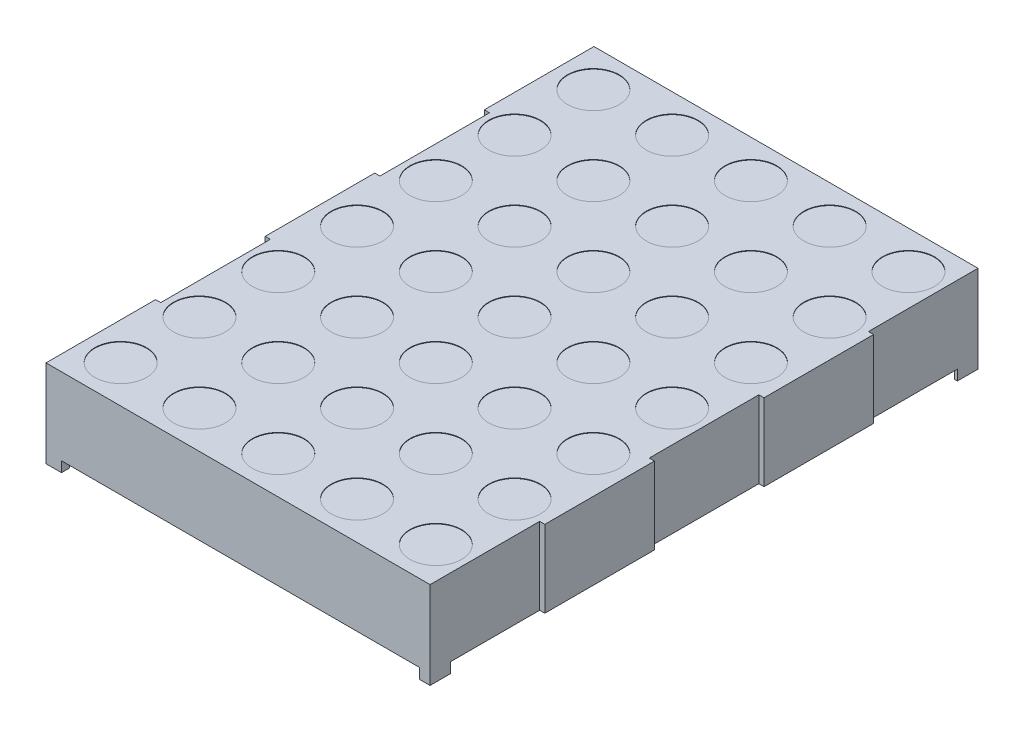
from build123d import *

# Parameters (mm, degrees)
EXTRUDE1_DEPTH     = 18.825
SKETCH3_W          = 34.65
SKETCH3_H          = 1
CUT_EXTRUDE1_DEPTH = 54
SKETCH2_R          = 2.5
CUT_EXTRUDE2_DEPTH = 0.05
SKETCH4_R          = 0.25
EXTRUDE2_DEPTH     = 1
SKETCH4_3_R        = 0.25
EXTRUDE3_DEPTH     = 4
SKETCH4_4_W        = 0.75
SKETCH4_4_H        = 1.25
CUT_EXTRUDE3_DEPTH = 1
SKETCH2_4_W        = 0.5
SKETCH2_4_H        = 10.6
CUT_EXTRUDE5_DEPTH = 13.45
SKETCH5_W          = 0.025316456
SKETCH5_H          = 0.026582278
CUT_EXTRUDE6_DEPTH = 0.01


with BuildPart() as part:
    # Sketch1 → Extrude1 (new body, symmetric)
    with BuildSketch(Plane(origin=(0, 0, 0), x_dir=(0, 0, -1), z_dir=(1, 0, 0))):
        Polygon((26.5, 4.225), (-26.5, 4.225), (20.227810651, -3.225), (24.5, -3.225), (24.5, -3.906132075), (26.5, -4.225), align=None)
        Polygon((20.227810651, -3.225), (-26.5, 4.225), (-26.5, -4.225), (-24.5, -4.225), (-24.5, -3.225), align=None)
        Polygon((26.5, -4.225), (24.5, -3.906132075), (24.5, -4.225), align=None)
    extrude(amount=EXTRUDE1_DEPTH, both=True)

    # Sketch3 → Cut-Extrude1 (cut, through all)
    with BuildSketch(Plane.XY.offset(26.5)):
        with Locations((0, -3.725)):
            Rectangle(SKETCH3_W, SKETCH3_H)
    extrude(amount=-CUT_EXTRUDE1_DEPTH, mode=Mode.SUBTRACT)

    # Sketch2 → Cut-Extrude2 (cut)
    with BuildSketch(Plane(origin=(0, 4.225, 0), x_dir=(-1, 0, 0), z_dir=(0, 1, 0))):
        with Locations(Location((15.24, -22.86, 0), (0, 0, 90))):  # turned: the seam where the file's is
            Circle(SKETCH2_R)
        with Locations(Location((7.62, -22.86, 0), (0, 0, 90))):  # turned: the seam where the file's is
            Circle(SKETCH2_R)
        with Locations(Location((0, -22.86, 0), (0, 0, 90))):  # turned: the seam where the file's is
            Circle(SKETCH2_R)
        with Locations(Location((-7.62, -22.86, 0), (0, 0, 90))):  # turned: the seam where the file's is
            Circle(SKETCH2_R)
        with Locations(Location((-15.24, -22.86, 0), (0, 0, 90))):  # turned: the seam where the file's is
            Circle(SKETCH2_R)
        with Locations(Location((-15.24, -15.24, 0), (0, 0, 90))):  # turned: the seam where the file's is
            Circle(SKETCH2_R)
        with Locations(Location((-7.62, -15.24, 0), (0, 0, 90))):  # turned: the seam where the file's is
            Circle(SKETCH2_R)
        with Locations(Location((0, -15.24, 0), (0, 0, 90))):  # turned: the seam where the file's is
            Circle(SKETCH2_R)
        with Locations(Location((7.62, -15.24, 0), (0, 0, 90))):  # turned: the seam where the file's is
            Circle(SKETCH2_R)
        with Locations(Location((15.24, -15.24, 0), (0, 0, 90))):  # turned: the seam where the file's is
            Circle(SKETCH2_R)
        with Locations(Location((15.24, -7.62, 0), (0, 0, 90))):  # turned: the seam where the file's is
            Circle(SKETCH2_R)
        with Locations(Location((7.62, -7.62, 0), (0, 0, 90))):  # turned: the seam where the file's is
            Circle(SKETCH2_R)
        with Locations(Location((0, -7.62, 0), (0, 0, 90))):  # turned: the seam where the file's is
            Circle(SKETCH2_R)
        with Locations(Location((-7.62, -7.62, 0), (0, 0, 90))):  # turned: the seam where the file's is
            Circle(SKETCH2_R)
        with Locations(Location((-15.24, -7.62, 0), (0, 0, 90))):  # turned: the seam where the file's is
            Circle(SKETCH2_R)
        with Locations(Location((-15.24, 0, 0), (0, 0, 90))):  # turned: the seam where the file's is
            Circle(SKETCH2_R)
        with Locations(Location((-7.62, 0, 0), (0, 0, 90))):  # turned: the seam where the file's is
            Circle(SKETCH2_R)
        with Locations(Location((0, 0, 0), (0, 0, 90))):  # turned: the seam where the file's is
            Circle(SKETCH2_R)
        with Locations(Location((7.62, 0, 0), (0, 0, 90))):  # turned: the seam where the file's is
            Circle(SKETCH2_R)
        with Locations(Location((15.24, 0, 0), (0, 0, 90))):  # turned: the seam where the file's is
            Circle(SKETCH2_R)
        with Locations(Location((15.24, 7.62, 0), (0, 0, 90))):  # turned: the seam where the file's is
            Circle(SKETCH2_R)
        with Locations(Location((7.62, 7.62, 0), (0, 0, 90))):  # turned: the seam where the file's is
            Circle(SKETCH2_R)
        with Locations(Location((0, 7.62, 0), (0, 0, 90))):  # turned: the seam where the file's is
            Circle(SKETCH2_R)
        with Locations(Location((-7.62, 7.62, 0), (0, 0, 90))):  # turned: the seam where the file's is
            Circle(SKETCH2_R)
        with Locations(Location((-15.24, 7.62, 0), (0, 0, 90))):  # turned: the seam where the file's is
            Circle(SKETCH2_R)
        with Locations(Location((-15.24, 15.24, 0), (0, 0, 90))):  # turned: the seam where the file's is
            Circle(SKETCH2_R)
        with Locations(Location((-7.62, 15.24, 0), (0, 0, 90))):  # turned: the seam where the file's is
            Circle(SKETCH2_R)
        with Locations(Location((0, 15.24, 0), (0, 0, 90))):  # turned: the seam where the file's is
            Circle(SKETCH2_R)
        with Locations(Location((7.62, 15.24, 0), (0, 0, 90))):  # turned: the seam where the file's is
            Circle(SKETCH2_R)
        with Locations(Location((15.24, 15.24, 0), (0, 0, 90))):  # turned: the seam where the file's is
            Circle(SKETCH2_R)
        with Locations(Location((15.24, 22.86, 0), (0, 0, 90))):  # turned: the seam where the file's is
            Circle(SKETCH2_R)
        with Locations(Location((7.62, 22.86, 0), (0, 0, 90))):  # turned: the seam where the file's is
            Circle(SKETCH2_R)
        with Locations(Location((0, 22.86, 0), (0, 0, 90))):  # turned: the seam where the file's is
            Circle(SKETCH2_R)
        with Locations(Location((-7.62, 22.86, 0), (0, 0, 90))):  # turned: the seam where the file's is
            Circle(SKETCH2_R)
        with Locations(Location((-15.24, 22.86, 0), (0, 0, 90))):  # turned: the seam where the file's is
            Circle(SKETCH2_R)
    extrude(amount=-CUT_EXTRUDE2_DEPTH, mode=Mode.SUBTRACT)

    # Sketch4 → Extrude2 (add)
    with BuildSketch(Plane.XZ.offset(4.225)):
        with Locations((-7.62, 19.05)):
            Circle(SKETCH4_R)
        with Locations(Location((-5.08, 19.05, 0), (0, 0, 270))):  # turned: the seam where the file's is
            Circle(SKETCH4_R)
        with Locations(Location((-2.54, 19.05, 0), (0, 0, 270))):  # turned: the seam where the file's is
            Circle(SKETCH4_R)
        with Locations(Location((7.62, 19.05, 0), (0, 0, 270))):  # turned: the seam where the file's is
            Circle(SKETCH4_R)
        with Locations(Location((0, 19.05, 0), (0, 0, 270))):  # turned: the seam where the file's is
            Circle(SKETCH4_R)
        with Locations(Location((2.54, 19.05, 0), (0, 0, 270))):  # turned: the seam where the file's is
            Circle(SKETCH4_R)
        with Locations(Location((5.08, 19.05, 0), (0, 0, 270))):  # turned: the seam where the file's is
            Circle(SKETCH4_R)
        with Locations(Location((5.08, -19.05, 0), (0, 0, 270))):  # turned: the seam where the file's is
            Circle(SKETCH4_R)
        with Locations(Location((2.54, -19.05, 0), (0, 0, 270))):  # turned: the seam where the file's is
            Circle(SKETCH4_R)
        with Locations(Location((0, -19.05, 0), (0, 0, 270))):  # turned: the seam where the file's is
            Circle(SKETCH4_R)
        with Locations(Location((7.62, -19.05, 0), (0, 0, 270))):  # turned: the seam where the file's is
            Circle(SKETCH4_R)
        with Locations(Location((-2.54, -19.05, 0), (0, 0, 270))):  # turned: the seam where the file's is
            Circle(SKETCH4_R)
        with Locations(Location((-5.08, -19.05, 0), (0, 0, 270))):  # turned: the seam where the file's is
            Circle(SKETCH4_R)
        with Locations(Location((-7.62, -19.05, 0), (0, 0, 270))):  # turned: the seam where the file's is
            Circle(SKETCH4_R)
    extrude(amount=-EXTRUDE2_DEPTH)

    # Sketch4_3 → Extrude3 (add)
    with BuildSketch(Plane.XZ.offset(4.225)):
        with Locations((-7.62, 19.05)):
            Circle(SKETCH4_3_R)
        with Locations((-5.08, 19.05)):
            Circle(SKETCH4_3_R)
        with Locations((-2.54, 19.05)):
            Circle(SKETCH4_3_R)
        with Locations((7.62, 19.05)):
            Circle(SKETCH4_3_R)
        with Locations((0, 19.05)):
            Circle(SKETCH4_3_R)
        with Locations((2.54, 19.05)):
            Circle(SKETCH4_3_R)
        with Locations(Location((5.08, 19.05, 0), (0, 0, 270))):  # turned: the seam where the file's is
            Circle(SKETCH4_3_R)
        with Locations(Location((5.08, -19.05, 0), (0, 0, 180))):  # turned: the seam where the file's is
            Circle(SKETCH4_3_R)
        with Locations(Location((2.54, -19.05, 0), (0, 0, 180))):  # turned: the seam where the file's is
            Circle(SKETCH4_3_R)
        with Locations(Location((0, -19.05, 0), (0, 0, 180))):  # turned: the seam where the file's is
            Circle(SKETCH4_3_R)
        with Locations(Location((7.62, -19.05, 0), (0, 0, 180))):  # turned: the seam where the file's is
            Circle(SKETCH4_3_R)
        with Locations(Location((-2.54, -19.05, 0), (0, 0, 270))):  # turned: the seam where the file's is
            Circle(SKETCH4_3_R)
        with Locations(Location((-5.08, -19.05, 0), (0, 0, 270))):  # turned: the seam where the file's is
            Circle(SKETCH4_3_R)
        with Locations(Location((-7.62, -19.05, 0), (0, 0, 270))):  # turned: the seam where the file's is
            Circle(SKETCH4_3_R)
    extrude(amount=EXTRUDE3_DEPTH)

    # Sketch4_4 → Cut-Extrude3 (cut)
    with BuildSketch(Plane.XZ.offset(4.225)):
        with Locations((-17.7, 25.125)):
            Rectangle(SKETCH4_4_W, SKETCH4_4_H)
        with Locations((17.7, 25.125)):
            Rectangle(SKETCH4_4_W, SKETCH4_4_H)
        with Locations((17.7, -25.125)):
            Rectangle(SKETCH4_4_W, SKETCH4_4_H)
        with Locations((-17.7, -25.125)):
            Rectangle(SKETCH4_4_W, SKETCH4_4_H)
    extrude(amount=-CUT_EXTRUDE3_DEPTH, mode=Mode.SUBTRACT)

    # Sketch2_4 → Cut-Extrude5 (cut, through all)
    with BuildSketch(Plane(origin=(0, 4.225, 0), x_dir=(-1, 0, 0), z_dir=(0, 1, 0))):
        with Locations((18.575, -10.6)):
            Rectangle(SKETCH2_4_W, SKETCH2_4_H)
        with Locations((18.575, 10.6)):
            Rectangle(SKETCH2_4_W, SKETCH2_4_H)
        with Locations((-18.575, 21.2)):
            Rectangle(SKETCH2_4_W, SKETCH2_4_H)
        with Locations((-18.575, 0)):
            Rectangle(SKETCH2_4_W, SKETCH2_4_H)
        with Locations((-18.575, -21.2)):
            Rectangle(SKETCH2_4_W, SKETCH2_4_H)
    extrude(amount=-CUT_EXTRUDE5_DEPTH, mode=Mode.SUBTRACT)

    # Sketch5 → Cut-Extrude6 (cut)
    with BuildSketch(Plane.XZ.offset(3.225)):
        Polygon((0.322151899, 18.267512561), (0.345609177, 18.342196105), (0.370352057, 18.342196105), (0.386768196, 18.291859871), (0.402294304, 18.342196105), (0.428026108, 18.342196105), (0.451265823, 18.267512561), (0.426087816, 18.267512561), (0.413093354, 18.318995947), (0.396677215, 18.267512561), (0.375178006, 18.267512561), (0.358860759, 18.318995947), (0.346044304, 18.267512561), align=None)
        Polygon((0.187974684, 18.267512561), (0.211431962, 18.342196105), (0.236174842, 18.342196105), (0.252590981, 18.291859871), (0.268117089, 18.342196105), (0.293848892, 18.342196105), (0.317088608, 18.267512561), (0.291910601, 18.267512561), (0.278916139, 18.318995947), (0.2625, 18.267512561), (0.241000791, 18.267512561), (0.224683544, 18.318995947), (0.211867089, 18.267512561), align=None)
        Polygon((0.053797468, 18.267512561), (0.077254747, 18.342196105), (0.101997627, 18.342196105), (0.118413766, 18.291859871), (0.133939873, 18.342196105), (0.159671677, 18.342196105), (0.182911392, 18.267512561), (0.157733386, 18.267512561), (0.144738924, 18.318995947), (0.128322785, 18.267512561), (0.106823576, 18.267512561), (0.090506329, 18.318995947), (0.077689873, 18.267512561), align=None)
        with Locations((0.025949367, 18.328904966)):
            Rectangle(SKETCH5_W, SKETCH5_H)
        with BuildLine():
            add(Edge.make_bspline(
                [(-0.090506329, 18.311025219), (-0.090469801, 18.312247334), (-0.090398072, 18.314647158), (-0.08978891, 18.318155124), (-0.088793386, 18.321478407), (-0.087429047, 18.324641123), (-0.085615059, 18.327596489), (-0.083460046, 18.330415056), (-0.080848131, 18.332999017), (-0.077911095, 18.335437779), (-0.074613168, 18.337620173), (-0.071010546, 18.339520312), (-0.067140226, 18.34114503), (-0.062986206, 18.34247672), (-0.058540628, 18.343467487), (-0.053822851, 18.344190805), (-0.048829503, 18.344664312), (-0.045405915, 18.344706254), (-0.043651108, 18.344727751)],
                knots=[0, 0, 0, 0, 0.907421153, 1.781872267, 2.635683434, 3.480115191, 4.332689235, 5.205575272, 6.109500117, 7.055808355, 8.037942167, 9.041423561, 10.07750834, 11.152467461, 12.277657752, 13.45734338, 14.696726425, 16, 16, 16, 16], degree=3))
            add(Edge.make_bspline(
                [(-0.043651108, 18.344727751), (-0.041633123, 18.344700486), (-0.037724937, 18.344647683), (-0.032057369, 18.344262309), (-0.026793902, 18.34357436), (-0.021896155, 18.342617779), (-0.017291855, 18.341414494), (-0.01285851, 18.34012385), (-0.008577218, 18.33865927), (-0.005804126, 18.337559134), (-0.00443038, 18.337014143)],
                knots=[0, 0, 0, 0, 1.203182053, 2.33017619, 3.384818652, 4.366208123, 5.30340534, 6.221361684, 7.118890722, 8, 8, 8, 8], degree=3))
            Line((-0.00443038, 18.337014143), (-0.00443038, 18.313082181))
            Line((-0.00443038, 18.313082181), (-0.007278481, 18.313082181))
            add(Edge.make_bspline(
                [(-0.007278481, 18.313082181), (-0.008644044, 18.314163144), (-0.011367154, 18.316318723), (-0.015794112, 18.319087078), (-0.020453124, 18.321460088), (-0.025291518, 18.323442711), (-0.030192886, 18.325018325), (-0.035061954, 18.32614523), (-0.039830936, 18.326884595), (-0.042989258, 18.326966156), (-0.044541139, 18.327006232)],
                knots=[0, 0, 0, 0, 1.030738938, 2.055426519, 3.085610749, 4.123842265, 5.148648843, 6.130724483, 7.081507926, 8, 8, 8, 8], degree=3))
            add(Edge.make_bspline(
                [(-0.044541139, 18.327006232), (-0.044969885, 18.327004931), (-0.045887798, 18.327002147), (-0.047356946, 18.326880832), (-0.049013289, 18.326752988), (-0.050794028, 18.326556873), (-0.052581232, 18.326325729), (-0.05424148, 18.325979261), (-0.055742242, 18.32561011), (-0.056648911, 18.325242845), (-0.057080696, 18.325067941)],
                knots=[0, 0, 0, 0, 0.806537132, 1.726733348, 2.77251655, 3.932999672, 5.098049949, 6.161349231, 7.124375527, 8, 8, 8, 8], degree=3))
            add(Edge.make_bspline(
                [(-0.057080696, 18.325067941), (-0.057560183, 18.324839705), (-0.058502475, 18.324391174), (-0.059805006, 18.323577264), (-0.060975491, 18.322682519), (-0.062036193, 18.321720786), (-0.062898588, 18.320557798), (-0.063519749, 18.319158527), (-0.06386432, 18.317509234), (-0.063903392, 18.316334072), (-0.063924051, 18.315712719)],
                knots=[0, 0, 0, 0, 1.02474257, 2.013837243, 2.958431669, 3.867978675, 4.769292696, 5.732237074, 6.800947934, 8, 8, 8, 8], degree=3))
            add(Edge.make_bspline(
                [(-0.063924051, 18.315712719), (-0.063892589, 18.315166853), (-0.063830727, 18.314093519), (-0.063249221, 18.31256509), (-0.062365174, 18.311144954), (-0.061085759, 18.309879617), (-0.059472081, 18.308753505), (-0.057541093, 18.307742742), (-0.055267243, 18.306906985), (-0.05363003, 18.306469113), (-0.052768987, 18.306238827)],
                knots=[0, 0, 0, 0, 0.825427492, 1.623033598, 2.45033906, 3.348940377, 4.33183287, 5.428402891, 6.647546779, 8, 8, 8, 8], degree=3))
            add(Edge.make_bspline(
                [(-0.052768987, 18.306238827), (-0.050799747, 18.305793622), (-0.046764535, 18.304881344), (-0.040624722, 18.30369389), (-0.034486019, 18.302468019), (-0.030529762, 18.301253705), (-0.028599684, 18.300661295)],
                knots=[0, 0, 0, 0, 0.976118991, 2.000185432, 3.024380873, 4, 4, 4, 4], degree=3))
            add(Edge.make_bspline(
                [(-0.028599684, 18.300661295), (-0.027561531, 18.300307573), (-0.025540669, 18.299619018), (-0.022641477, 18.29846637), (-0.019998229, 18.297161235), (-0.01754069, 18.295839197), (-0.015348026, 18.29435914), (-0.013353392, 18.292826381), (-0.011600732, 18.291173576), (-0.010074294, 18.289424084), (-0.008731428, 18.287587722), (-0.007578018, 18.28564058), (-0.006616996, 18.283574131), (-0.005793604, 18.281418733), (-0.005182377, 18.279144198), (-0.004759941, 18.276767781), (-0.004461878, 18.274284295), (-0.004441022, 18.272589959), (-0.00443038, 18.271725378)],
                knots=[0, 0, 0, 0, 1.287376879, 2.505999703, 3.65855109, 4.746193839, 5.778582289, 6.760029101, 7.696159662, 8.601061861, 9.48181646, 10.363080883, 11.252765705, 12.153987336, 13.068239035, 14.012364187, 14.985753787, 16, 16, 16, 16], degree=3))
            add(Edge.make_bspline(
                [(-0.00443038, 18.271725378), (-0.00446768, 18.270569231), (-0.004541087, 18.268293956), (-0.005142537, 18.264964934), (-0.006169047, 18.261816115), (-0.007555407, 18.258812959), (-0.0093829, 18.255998696), (-0.011575023, 18.25332121), (-0.014185333, 18.250828713), (-0.01717066, 18.248530077), (-0.020457507, 18.246451271), (-0.023991512, 18.244614564), (-0.027770364, 18.243108116), (-0.031750249, 18.241826885), (-0.035969641, 18.24087449), (-0.040406612, 18.240154912), (-0.045080474, 18.239741912), (-0.048271885, 18.239690636), (-0.049901108, 18.23966446)],
                knots=[0, 0, 0, 0, 0.894901293, 1.761149761, 2.608783409, 3.453876344, 4.314933854, 5.200038827, 6.12799933, 7.103249695, 8.113098521, 9.136064399, 10.182719798, 11.259667356, 12.370545059, 13.528828137, 14.738461593, 16, 16, 16, 16], degree=3))
            add(Edge.make_bspline(
                [(-0.049901108, 18.23966446), (-0.051569759, 18.239686853), (-0.054904233, 18.2397316), (-0.059886206, 18.24010657), (-0.064843621, 18.240673071), (-0.069715185, 18.241472525), (-0.074397692, 18.242490181), (-0.078814306, 18.243576139), (-0.082893276, 18.244816529), (-0.085467001, 18.245770575), (-0.086708861, 18.246230916)],
                knots=[0, 0, 0, 0, 1.065379838, 2.128953261, 3.188461447, 4.250817766, 5.279613205, 6.247547721, 7.154416075, 8, 8, 8, 8], degree=3))
            Line((-0.086708861, 18.246230916), (-0.086708861, 18.268778384))
            Line((-0.086708861, 18.268778384), (-0.083880538, 18.268778384))
            add(Edge.make_bspline(
                [(-0.083880538, 18.268778384), (-0.082807578, 18.26797818), (-0.080613348, 18.266341742), (-0.076954595, 18.264255766), (-0.072990535, 18.262306252), (-0.068725633, 18.260584458), (-0.064253093, 18.259163858), (-0.059675547, 18.258134813), (-0.055048482, 18.25749569), (-0.051946891, 18.257422558), (-0.05039557, 18.257385979)],
                knots=[0, 0, 0, 0, 0.89224925, 1.824673196, 2.804309561, 3.838364047, 4.890042674, 5.931526337, 6.965412421, 8, 8, 8, 8], degree=3))
            add(Edge.make_bspline(
                [(-0.05039557, 18.257385979), (-0.04930027, 18.257410189), (-0.047110524, 18.257458589), (-0.043836117, 18.257807843), (-0.040601325, 18.258479585), (-0.038558427, 18.259293921), (-0.037539557, 18.259700061)],
                knots=[0, 0, 0, 0, 0.998993879, 1.997209027, 3.00113285, 4, 4, 4, 4], degree=3))
            add(Edge.make_bspline(
                [(-0.037539557, 18.259700061), (-0.037106078, 18.259901544), (-0.036239408, 18.260304375), (-0.035032405, 18.261076701), (-0.033929101, 18.262006419), (-0.032928096, 18.263058813), (-0.03208004, 18.264228147), (-0.03144238, 18.265497907), (-0.031081561, 18.266859885), (-0.031035724, 18.267794054), (-0.031012658, 18.268264143)],
                knots=[0, 0, 0, 0, 1.005454979, 2.010239304, 3.005296729, 4.036100111, 5.060531193, 6.034954812, 7.011155677, 8, 8, 8, 8], degree=3))
            add(Edge.make_bspline(
                [(-0.031012658, 18.268264143), (-0.031047453, 18.268902074), (-0.031113941, 18.270121102), (-0.031713939, 18.271834799), (-0.032711608, 18.27329791), (-0.033864707, 18.274290904), (-0.034981686, 18.274989664), (-0.036022203, 18.275494903), (-0.037221654, 18.276008326), (-0.038599103, 18.276497523), (-0.040134238, 18.27699157), (-0.04184316, 18.27746624), (-0.043725768, 18.277915799), (-0.045041658, 18.278201951), (-0.045727848, 18.278351169)],
                knots=[0, 0, 0, 0, 1.174343879, 2.244064321, 3.303704314, 4.407076671, 5.02483983, 5.732197225, 6.53898402, 7.431906431, 8.428480183, 9.514816237, 10.704066255, 12, 12, 12, 12], degree=3))
            add(Edge.make_bspline(
                [(-0.045727848, 18.278351169), (-0.047560473, 18.278727889), (-0.051161176, 18.279468061), (-0.056566251, 18.280562358), (-0.062059305, 18.281874875), (-0.065729855, 18.283004087), (-0.067642405, 18.283592466)],
                knots=[0, 0, 0, 0, 0.995788186, 1.956503735, 2.935230479, 4, 4, 4, 4], degree=3))
            add(Edge.make_bspline(
                [(-0.067642405, 18.283592466), (-0.068588962, 18.283911708), (-0.070440579, 18.284536195), (-0.073081177, 18.285622514), (-0.07552835, 18.286796371), (-0.077794984, 18.28803834), (-0.07987035, 18.289380774), (-0.08175664, 18.290806107), (-0.083454597, 18.292310889), (-0.084943345, 18.293926609), (-0.086272103, 18.295636958), (-0.087384447, 18.297487571), (-0.088380032, 18.299431099), (-0.089133187, 18.301524543), (-0.089757696, 18.30372307), (-0.090179439, 18.306055005), (-0.090473802, 18.308499223), (-0.090495366, 18.310173822), (-0.090506329, 18.311025219)],
                knots=[0, 0, 0, 0, 1.237326419, 2.420410185, 3.534642089, 4.598489486, 5.620241961, 6.59385002, 7.525152549, 8.426792174, 9.312230456, 10.203151844, 11.098070343, 12.012931196, 12.954244379, 13.926618287, 14.945853925, 16, 16, 16, 16], degree=3))
        make_face()
        with BuildLine():
            Line((-0.182911392, 18.342196105), (-0.158860759, 18.342196105))
            Line((-0.158860759, 18.342196105), (-0.158860759, 18.334363827))
            add(Edge.make_bspline(
                [(-0.158860759, 18.334363827), (-0.157767566, 18.335172622), (-0.155659904, 18.336731967), (-0.152485345, 18.338809028), (-0.149467045, 18.340593451), (-0.146536693, 18.342116568), (-0.143530416, 18.343328739), (-0.140292282, 18.344147119), (-0.136790686, 18.344649843), (-0.134363616, 18.344701205), (-0.133109177, 18.344727751)],
                knots=[0, 0, 0, 0, 1.150945962, 2.219006967, 3.209666795, 4.118194914, 5.012574058, 5.946577101, 6.93868214, 8, 8, 8, 8], degree=3))
            add(Edge.make_bspline(
                [(-0.133109177, 18.344727751), (-0.132092902, 18.344704803), (-0.130113921, 18.344660117), (-0.127235622, 18.344318396), (-0.124533656, 18.343769987), (-0.122004819, 18.343001581), (-0.119655119, 18.34199855), (-0.117511439, 18.340726915), (-0.115508862, 18.339294202), (-0.113726915, 18.337587836), (-0.112111369, 18.335689917), (-0.110728798, 18.333557508), (-0.109551093, 18.331224569), (-0.108609993, 18.328672719), (-0.107854904, 18.325914414), (-0.107330972, 18.322935167), (-0.107010379, 18.319748039), (-0.10697844, 18.317552909), (-0.106962025, 18.316424745)],
                knots=[0, 0, 0, 0, 1.108959949, 2.159465255, 3.158589008, 4.114545495, 5.039534357, 5.93921201, 6.830099133, 7.720870013, 8.624681761, 9.544731627, 10.487599671, 11.471264588, 12.508152322, 13.604835107, 14.769030043, 16, 16, 16, 16], degree=3))
            Line((-0.106962025, 18.316424745), (-0.106962025, 18.267512561))
            Line((-0.106962025, 18.267512561), (-0.131012658, 18.267512561))
            Line((-0.131012658, 18.267512561), (-0.131012658, 18.305091675))
            add(Edge.make_bspline(
                [(-0.131012658, 18.305091675), (-0.131014294, 18.306008146), (-0.131017424, 18.307762362), (-0.131099763, 18.310268168), (-0.131220664, 18.312536341), (-0.131359369, 18.314578369), (-0.131612385, 18.31642512), (-0.131990094, 18.318091281), (-0.13246092, 18.319610883), (-0.132925239, 18.320517585), (-0.133148734, 18.320954017)],
                knots=[0, 0, 0, 0, 1.361401701, 2.605856924, 3.723918663, 4.735739235, 5.645738665, 6.489217889, 7.27279937, 8, 8, 8, 8], degree=3))
            add(Edge.make_bspline(
                [(-0.133148734, 18.320954017), (-0.133378743, 18.321352723), (-0.13383092, 18.322136544), (-0.134751184, 18.323142855), (-0.135830026, 18.323986605), (-0.13710723, 18.324644706), (-0.138596797, 18.325135209), (-0.140317656, 18.325515781), (-0.142309397, 18.325687658), (-0.143716865, 18.325722149), (-0.144462025, 18.325740409)],
                knots=[0, 0, 0, 0, 0.849004071, 1.669068917, 2.503060811, 3.370079215, 4.310762265, 5.396376419, 6.621555549, 8, 8, 8, 8], degree=3))
            add(Edge.make_bspline(
                [(-0.144462025, 18.325740409), (-0.145002968, 18.32572057), (-0.146114384, 18.325679809), (-0.147831837, 18.325488268), (-0.149621097, 18.325089109), (-0.152139766, 18.324444164), (-0.155304975, 18.32325031), (-0.15766451, 18.321897163), (-0.158860759, 18.321211137)],
                knots=[0, 0, 0, 0, 0.638062719, 1.310959128, 2.033463623, 2.796942592, 4.376095945, 6, 6, 6, 6], degree=3))
            Line((-0.158860759, 18.321211137), (-0.158860759, 18.267512561))
            Line((-0.158860759, 18.267512561), (-0.182911392, 18.267512561))
            Line((-0.182911392, 18.267512561), (-0.182911392, 18.342196105))
        make_face()
        with BuildLine():
            Line((-0.280379747, 18.342196105), (-0.256329114, 18.342196105))
            Line((-0.256329114, 18.342196105), (-0.256329114, 18.304616992))
            add(Edge.make_bspline(
                [(-0.256329114, 18.304616992), (-0.256304108, 18.303087002), (-0.256254136, 18.300029511), (-0.255977585, 18.296266416), (-0.255593098, 18.293424877), (-0.255225559, 18.291593288), (-0.254793687, 18.290045172), (-0.254381426, 18.28915941), (-0.254193038, 18.28875465)],
                knots=[0, 0, 0, 0, 1.709111167, 3.415443484, 4.21113913, 4.910175115, 5.501990373, 6, 6, 6, 6], degree=3))
            add(Edge.make_bspline(
                [(-0.254193038, 18.28875465), (-0.253948577, 18.288356587), (-0.253469277, 18.287576129), (-0.252531926, 18.286563252), (-0.251438143, 18.285733884), (-0.250166967, 18.285054417), (-0.248678858, 18.284575229), (-0.246954941, 18.284222475), (-0.244974756, 18.284011921), (-0.243565927, 18.283983367), (-0.242820411, 18.283968257)],
                knots=[0, 0, 0, 0, 0.860202684, 1.686548532, 2.528236983, 3.382486038, 4.33249885, 5.401154041, 6.624757403, 8, 8, 8, 8], degree=3))
            add(Edge.make_bspline(
                [(-0.242820411, 18.283968257), (-0.241689522, 18.284028358), (-0.239381827, 18.284150999), (-0.236506517, 18.284817666), (-0.234189179, 18.28567763), (-0.232331462, 18.286428065), (-0.23042374, 18.287402166), (-0.229144198, 18.288123607), (-0.228481013, 18.28849753)],
                knots=[0, 0, 0, 0, 1.33818541, 2.730705359, 3.468371228, 4.262126284, 5.099261778, 6, 6, 6, 6], degree=3))
            Line((-0.228481013, 18.28849753), (-0.228481013, 18.342196105))
            Line((-0.228481013, 18.342196105), (-0.20443038, 18.342196105))
            Line((-0.20443038, 18.342196105), (-0.20443038, 18.267512561))
            Line((-0.20443038, 18.267512561), (-0.228481013, 18.267512561))
            Line((-0.228481013, 18.267512561), (-0.228481013, 18.27534484))
            add(Edge.make_bspline(
                [(-0.228481013, 18.27534484), (-0.229538419, 18.274538688), (-0.231596724, 18.272969466), (-0.234775962, 18.270929045), (-0.23785986, 18.269130276), (-0.240912869, 18.26761746), (-0.244027824, 18.266410685), (-0.247290583, 18.265599696), (-0.250706989, 18.265055893), (-0.253043704, 18.265006199), (-0.254232595, 18.264980916)],
                knots=[0, 0, 0, 0, 1.126119141, 2.192057864, 3.198061997, 4.149848529, 5.076251285, 6.021887753, 6.99356175, 8, 8, 8, 8], degree=3))
            add(Edge.make_bspline(
                [(-0.254232595, 18.264980916), (-0.25522886, 18.265006316), (-0.257173746, 18.265055902), (-0.260008596, 18.265365454), (-0.262679702, 18.265916677), (-0.265173087, 18.266712533), (-0.267508773, 18.267703893), (-0.269682445, 18.268907872), (-0.271668294, 18.270371153), (-0.273496446, 18.272031092), (-0.275135546, 18.273922389), (-0.276532456, 18.276051767), (-0.277736818, 18.278388688), (-0.278686083, 18.280951325), (-0.279477407, 18.283717597), (-0.27998217, 18.286716227), (-0.280339823, 18.289926112), (-0.280366173, 18.292142262), (-0.280379747, 18.293283922)],
                knots=[0, 0, 0, 0, 1.08828964, 2.12453497, 3.110382522, 4.062402335, 4.978696626, 5.878225494, 6.769849763, 7.667011675, 8.57076823, 9.495541561, 10.442454184, 11.436213583, 12.475881554, 13.580560132, 14.753614518, 16, 16, 16, 16], degree=3))
            Line((-0.280379747, 18.293283922), (-0.280379747, 18.342196105))
        make_face()
        Polygon((-0.375316456, 18.342196105), (-0.303164557, 18.342196105), (-0.303164557, 18.242196105), (-0.328481013, 18.242196105), (-0.328481013, 18.323208764), (-0.375316456, 18.323208764), align=None)
        Polygon((-0.462658228, 18.342196105), (-0.390506329, 18.342196105), (-0.390506329, 18.242196105), (-0.462658228, 18.242196105), (-0.462658228, 18.261183447), (-0.415822785, 18.261183447), (-0.415822785, 18.278904966), (-0.458860759, 18.278904966), (-0.458860759, 18.297892308), (-0.415822785, 18.297892308), (-0.415822785, 18.323208764), (-0.462658228, 18.323208764), align=None)
        with BuildLine():
            add(Edge.make_bspline(
                [(-0.579113924, 18.292294998), (-0.579094609, 18.293442687), (-0.579056357, 18.295715573), (-0.578761165, 18.299080379), (-0.57823514, 18.302346055), (-0.577555959, 18.305530303), (-0.576633453, 18.308609231), (-0.575551739, 18.311616808), (-0.574242093, 18.314522302), (-0.572737241, 18.317323736), (-0.571087768, 18.319995839), (-0.569313019, 18.322516048), (-0.56746724, 18.324899266), (-0.565477927, 18.32709416), (-0.563398746, 18.329136179), (-0.561223217, 18.331026993), (-0.558918153, 18.332730424), (-0.55731099, 18.333753309), (-0.55650712, 18.334264935)],
                knots=[0, 0, 0, 0, 1.105570398, 2.18947457, 3.250358341, 4.290584537, 5.323553275, 6.344225964, 7.367641686, 8.3905646, 9.405808457, 10.390761353, 11.358902336, 12.307789878, 13.241960776, 14.165076779, 15.082208636, 16, 16, 16, 16], degree=3))
            add(Edge.make_bspline(
                [(-0.55650712, 18.334264935), (-0.555267933, 18.334977256), (-0.552783236, 18.336405533), (-0.548798778, 18.338071372), (-0.544677169, 18.339485595), (-0.540317988, 18.340499035), (-0.535679267, 18.34126887), (-0.530674456, 18.341817042), (-0.52526755, 18.342122544), (-0.521532557, 18.342171026), (-0.519600475, 18.342196105)],
                knots=[0, 0, 0, 0, 0.896321744, 1.797216976, 2.705381885, 3.628777036, 4.602292017, 5.655629376, 6.787275635, 8, 8, 8, 8], degree=3))
            Line((-0.519600475, 18.342196105), (-0.484177215, 18.342196105))
            Line((-0.484177215, 18.342196105), (-0.484177215, 18.242196105))
            Line((-0.484177215, 18.242196105), (-0.520609177, 18.242196105))
            add(Edge.make_bspline(
                [(-0.520609177, 18.242196105), (-0.522587873, 18.242212916), (-0.526404533, 18.24224534), (-0.531921849, 18.242660268), (-0.537024188, 18.243266031), (-0.541713768, 18.244160216), (-0.546016217, 18.245274797), (-0.549933509, 18.246663329), (-0.553549742, 18.248155946), (-0.555728277, 18.2494305), (-0.556784019, 18.250048162)],
                knots=[0, 0, 0, 0, 1.267083275, 2.444046388, 3.541868212, 4.55639609, 5.499737919, 6.385160515, 7.217431253, 8, 8, 8, 8], degree=3))
            add(Edge.make_bspline(
                [(-0.556784019, 18.250048162), (-0.557634972, 18.250584703), (-0.559327097, 18.251651617), (-0.561728312, 18.253433469), (-0.563957739, 18.255389546), (-0.566086242, 18.257441365), (-0.568066059, 18.259644251), (-0.569909259, 18.261982959), (-0.571613076, 18.264461053), (-0.573171039, 18.267070522), (-0.574591854, 18.269800574), (-0.57578116, 18.272673633), (-0.576830509, 18.275652163), (-0.577636046, 18.278761125), (-0.57833396, 18.281968961), (-0.578768694, 18.285310305), (-0.579055305, 18.288762794), (-0.57909422, 18.291107683), (-0.579113924, 18.292294998)],
                knots=[0, 0, 0, 0, 0.964065863, 1.917049184, 2.86229036, 3.805247319, 4.749389377, 5.698846072, 6.657678277, 7.629829384, 8.610569287, 9.604676042, 10.607940105, 11.6349849, 12.681042988, 13.752616828, 14.862056989, 16, 16, 16, 16], degree=3))
        make_face()
        with BuildLine():
            add(Edge.make_bspline(
                [(-0.552531646, 18.29213677), (-0.552488343, 18.29055834), (-0.55240473, 18.28751054), (-0.551699336, 18.283114896), (-0.550560086, 18.279071946), (-0.549222393, 18.27595953), (-0.547885002, 18.273686213), (-0.546757478, 18.272087942), (-0.545507812, 18.270573743), (-0.544117203, 18.269164903), (-0.542582019, 18.267857867), (-0.54092076, 18.266628956), (-0.539120719, 18.26550031), (-0.537847688, 18.264840304), (-0.537203323, 18.264506232)],
                knots=[0, 0, 0, 0, 1.694683197, 3.272273219, 4.767406206, 6.197615014, 6.895990032, 7.597410435, 8.296503208, 9.002591366, 9.720792421, 10.460154445, 11.220583224, 12, 12, 12, 12], degree=3))
            add(Edge.make_bspline(
                [(-0.537203323, 18.264506232), (-0.536528388, 18.264199718), (-0.535190619, 18.263592185), (-0.533120344, 18.262858099), (-0.531027643, 18.262295771), (-0.528833415, 18.261823348), (-0.526356655, 18.261546212), (-0.523434164, 18.261333536), (-0.519977491, 18.261196608), (-0.517490895, 18.261188038), (-0.516159019, 18.261183447)],
                knots=[0, 0, 0, 0, 0.826913061, 1.638999358, 2.447478739, 3.243919028, 4.140906711, 5.225381046, 6.513851968, 8, 8, 8, 8], degree=3))
            Line((-0.516159019, 18.261183447), (-0.509493671, 18.261183447))
            Line((-0.509493671, 18.261183447), (-0.509493671, 18.323208764))
            Line((-0.509493671, 18.323208764), (-0.516159019, 18.323208764))
            add(Edge.make_bspline(
                [(-0.516159019, 18.323208764), (-0.51691721, 18.323203718), (-0.518380945, 18.323193977), (-0.520497399, 18.323154874), (-0.522462161, 18.323094558), (-0.524269511, 18.323022715), (-0.525925648, 18.322907812), (-0.527413482, 18.322739215), (-0.528755832, 18.322594828), (-0.530323467, 18.322327708), (-0.532176615, 18.321911253), (-0.534337881, 18.321233162), (-0.536478414, 18.320382742), (-0.537866987, 18.319697778), (-0.538568038, 18.31935196)],
                knots=[0, 0, 0, 0, 1.186775798, 2.291144404, 3.313233901, 4.263515562, 5.122260739, 5.910868134, 6.60717912, 7.234883681, 8.398964994, 9.577230746, 10.776813768, 12, 12, 12, 12], degree=3))
            add(Edge.make_bspline(
                [(-0.538568038, 18.31935196), (-0.539151752, 18.319008483), (-0.540299689, 18.318333), (-0.541943833, 18.317227137), (-0.543430573, 18.315992138), (-0.544836635, 18.314709039), (-0.546089501, 18.313318586), (-0.547262794, 18.311868106), (-0.54827305, 18.310305712), (-0.549518045, 18.308112183), (-0.550737777, 18.305078813), (-0.551778537, 18.30111227), (-0.552415052, 18.29675226), (-0.552491785, 18.293714678), (-0.552531646, 18.29213677)],
                knots=[0, 0, 0, 0, 0.755109416, 1.485004392, 2.205961541, 2.908125208, 3.605307969, 4.290649036, 4.985852759, 5.676964147, 7.100721462, 8.614478074, 10.241350405, 12, 12, 12, 12], degree=3))
        make_face(mode=Mode.SUBTRACT)
        with Locations((-0.610759494, 18.328904966)):
            Rectangle(SKETCH5_W, SKETCH5_H)
        with BuildLine():
            add(Edge.make_bspline(
                [(-0.685403481, 18.344727751), (-0.683813375, 18.344705925), (-0.680692253, 18.344663083), (-0.676120809, 18.344186381), (-0.671756006, 18.343467914), (-0.667608387, 18.342449742), (-0.663701826, 18.3410934), (-0.660020773, 18.339475386), (-0.656631411, 18.33745758), (-0.654567681, 18.335880638), (-0.653540348, 18.335095631)],
                knots=[0, 0, 0, 0, 1.123606455, 2.205459211, 3.245124445, 4.248821949, 5.220056174, 6.165006393, 7.086533249, 8, 8, 8, 8], degree=3))
            add(Edge.make_bspline(
                [(-0.653540348, 18.335095631), (-0.652588601, 18.334240857), (-0.650688786, 18.332534614), (-0.648222853, 18.329563187), (-0.646099767, 18.326280143), (-0.644314215, 18.32267792), (-0.642883291, 18.318761192), (-0.641860157, 18.314516529), (-0.641240912, 18.309955749), (-0.641173746, 18.306807815), (-0.641139241, 18.305190568)],
                knots=[0, 0, 0, 0, 0.916457077, 1.82937027, 2.759194969, 3.714948755, 4.706655623, 5.743329475, 6.840637961, 8, 8, 8, 8], degree=3))
            add(Edge.make_bspline(
                [(-0.641139241, 18.305190568), (-0.641178001, 18.30348734), (-0.641253124, 18.30018626), (-0.641916883, 18.295414073), (-0.642986496, 18.290996392), (-0.644524054, 18.286944484), (-0.646454496, 18.283251292), (-0.648718989, 18.279879458), (-0.651339514, 18.276836533), (-0.653346653, 18.275091094), (-0.654351266, 18.274217466)],
                knots=[0, 0, 0, 0, 1.171797512, 2.271099083, 3.308930235, 4.294129479, 5.24602549, 6.17106565, 7.084581485, 8, 8, 8, 8], degree=3))
            add(Edge.make_bspline(
                [(-0.654351266, 18.274217466), (-0.655377179, 18.273449005), (-0.657441398, 18.2719028), (-0.660844242, 18.27000019), (-0.664471932, 18.268411996), (-0.668293668, 18.267135276), (-0.672268653, 18.266180659), (-0.676332207, 18.265487993), (-0.680476009, 18.265059311), (-0.683266389, 18.265007173), (-0.684671677, 18.264980916)],
                knots=[0, 0, 0, 0, 0.952046378, 1.915591786, 2.889970712, 3.892742799, 4.906722985, 5.925995921, 6.955492795, 8, 8, 8, 8], degree=3))
            add(Edge.make_bspline(
                [(-0.684671677, 18.264980916), (-0.685918482, 18.264997313), (-0.688370122, 18.265029556), (-0.691968962, 18.265360159), (-0.69542692, 18.265862097), (-0.698733839, 18.266600669), (-0.701900836, 18.267522286), (-0.704954975, 18.268554348), (-0.707914207, 18.26968958), (-0.709814852, 18.270573857), (-0.710759494, 18.271013352)],
                knots=[0, 0, 0, 0, 1.107549047, 2.177816721, 3.208424937, 4.210433793, 5.185680559, 6.13785309, 7.074491882, 8, 8, 8, 8], degree=3))
            Line((-0.710759494, 18.271013352), (-0.710759494, 18.291563194))
            Line((-0.710759494, 18.291563194), (-0.70741693, 18.291563194))
            add(Edge.make_bspline(
                [(-0.70741693, 18.291563194), (-0.706916353, 18.291147308), (-0.705831328, 18.290245855), (-0.704064496, 18.288799268), (-0.701894176, 18.287298978), (-0.700247147, 18.286404353), (-0.699367089, 18.285926327)],
                knots=[0, 0, 0, 0, 0.792743043, 1.718305972, 2.780820752, 4, 4, 4, 4], degree=3))
            add(Edge.make_bspline(
                [(-0.699367089, 18.285926327), (-0.698438153, 18.285487689), (-0.696532244, 18.284587728), (-0.693989036, 18.28371034), (-0.691785857, 18.283184971), (-0.689972197, 18.282919406), (-0.6880379, 18.282732548), (-0.686702754, 18.282712657), (-0.686016614, 18.282702435)],
                knots=[0, 0, 0, 0, 1.332360773, 2.733622135, 3.480580446, 4.268165618, 5.10999921, 6, 6, 6, 6], degree=3))
            add(Edge.make_bspline(
                [(-0.686016614, 18.282702435), (-0.685250975, 18.282721765), (-0.683767202, 18.282759228), (-0.681606835, 18.283039275), (-0.679582217, 18.283507367), (-0.677694179, 18.284185312), (-0.675940348, 18.285037078), (-0.674320324, 18.286078523), (-0.672826892, 18.287301795), (-0.671507951, 18.288743427), (-0.670315137, 18.290323167), (-0.66929596, 18.292057334), (-0.668383497, 18.293903919), (-0.66768856, 18.295908372), (-0.667128822, 18.298037146), (-0.666739892, 18.300300267), (-0.666497934, 18.302699777), (-0.666470016, 18.304346085), (-0.666455696, 18.305190568)],
                knots=[0, 0, 0, 0, 1.087372478, 2.107277257, 3.088614887, 4.033572876, 4.950837204, 5.852283781, 6.763600506, 7.684681617, 8.621202104, 9.570420019, 10.537986648, 11.542161979, 12.577980734, 13.661919757, 14.800668594, 16, 16, 16, 16], degree=3))
            add(Edge.make_bspline(
                [(-0.666455696, 18.305190568), (-0.666470471, 18.306054724), (-0.666499177, 18.307733736), (-0.666732691, 18.310175347), (-0.667148582, 18.312456779), (-0.66771983, 18.314582099), (-0.668444178, 18.316548117), (-0.669349295, 18.318345513), (-0.670385652, 18.320002321), (-0.67163021, 18.321464933), (-0.672994093, 18.322781254), (-0.674508985, 18.323917389), (-0.676168224, 18.324865534), (-0.677950405, 18.325669997), (-0.679883445, 18.326248395), (-0.681939982, 18.326685087), (-0.684129537, 18.326973643), (-0.685639891, 18.326995206), (-0.686412184, 18.327006232)],
                knots=[0, 0, 0, 0, 1.230336593, 2.390482092, 3.487897344, 4.52859895, 5.520747884, 6.465347575, 7.38981449, 8.296085817, 9.192433006, 10.084246191, 10.984321635, 11.908883871, 12.862027947, 13.850751296, 14.901019963, 16, 16, 16, 16], degree=3))
            add(Edge.make_bspline(
                [(-0.686412184, 18.327006232), (-0.687137949, 18.326997482), (-0.6885528, 18.326980425), (-0.6906198, 18.326770871), (-0.692577305, 18.3264641), (-0.694410447, 18.326024146), (-0.69611318, 18.325511596), (-0.697669514, 18.324938651), (-0.69908249, 18.324335524), (-0.69994378, 18.323867769), (-0.700356013, 18.32364389)],
                knots=[0, 0, 0, 0, 1.201052708, 2.34140671, 3.435973211, 4.479046096, 5.459661032, 6.378175262, 7.223757638, 8, 8, 8, 8], degree=3))
            add(Edge.make_bspline(
                [(-0.700356013, 18.32364389), (-0.701056218, 18.323213996), (-0.702410785, 18.322382354), (-0.704249513, 18.320980788), (-0.705894382, 18.319566528), (-0.706918894, 18.31861031), (-0.70741693, 18.318145473)],
                knots=[0, 0, 0, 0, 1.098601379, 2.125273733, 3.088655601, 4, 4, 4, 4], degree=3))
            Line((-0.70741693, 18.318145473), (-0.710759494, 18.318145473))
            Line((-0.710759494, 18.318145473), (-0.710759494, 18.338853542))
            add(Edge.make_bspline(
                [(-0.710759494, 18.338853542), (-0.709814104, 18.339291036), (-0.707923097, 18.34016613), (-0.705008518, 18.341320002), (-0.702020545, 18.342288162), (-0.698972172, 18.343191243), (-0.695800089, 18.343879605), (-0.692477058, 18.344372728), (-0.68899556, 18.34467364), (-0.686617171, 18.344709468), (-0.685403481, 18.344727751)],
                knots=[0, 0, 0, 0, 0.952012952, 1.904254716, 2.862729541, 3.822037426, 4.808956931, 5.82647221, 6.890850784, 8, 8, 8, 8], degree=3))
        make_face()
        with BuildLine():
            add(Edge.make_bspline(
                [(-0.803164557, 18.30489389), (-0.803139862, 18.306398796), (-0.803091723, 18.309332262), (-0.802552407, 18.313604053), (-0.801739627, 18.317640051), (-0.800567096, 18.32142726), (-0.799086703, 18.324984534), (-0.797235764, 18.328274327), (-0.795064759, 18.331327556), (-0.792573722, 18.334117441), (-0.78977252, 18.336615952), (-0.786698338, 18.338811205), (-0.783324511, 18.340624646), (-0.7797102, 18.342136737), (-0.775825548, 18.343305972), (-0.771671329, 18.344118689), (-0.767254195, 18.34465416), (-0.764215776, 18.344702811), (-0.762658228, 18.344727751)],
                knots=[0, 0, 0, 0, 1.120167703, 2.183507516, 3.201345984, 4.182878364, 5.131270247, 6.065524964, 6.98789854, 7.91635504, 8.84481154, 9.778033504, 10.722808862, 11.691211189, 12.691525459, 13.738229926, 14.840575679, 16, 16, 16, 16], degree=3))
            add(Edge.make_bspline(
                [(-0.762658228, 18.344727751), (-0.761100707, 18.344702729), (-0.758062341, 18.344653917), (-0.753644832, 18.344119585), (-0.749485737, 18.343301635), (-0.74559643, 18.342145534), (-0.741987684, 18.340618984), (-0.738617817, 18.338811936), (-0.735544052, 18.336615743), (-0.732742566, 18.334117551), (-0.730252248, 18.331327325), (-0.728078657, 18.328275142), (-0.726236243, 18.324979188), (-0.724718389, 18.321436142), (-0.723585065, 18.317635305), (-0.722761602, 18.313604863), (-0.722225394, 18.309332043), (-0.722176819, 18.306398722), (-0.722151899, 18.30489389)],
                knots=[0, 0, 0, 0, 1.15937715, 2.261678054, 3.308339936, 4.313313916, 5.277148057, 6.221884977, 7.155068972, 8.083487698, 9.011906424, 9.934242473, 10.868459181, 11.818729666, 12.798784262, 13.81658132, 14.879877871, 16, 16, 16, 16], degree=3))
            add(Edge.make_bspline(
                [(-0.722151899, 18.30489389), (-0.722177, 18.303382458), (-0.722226044, 18.300429429), (-0.722761711, 18.296130682), (-0.723578673, 18.292069586), (-0.724744205, 18.288257035), (-0.726250482, 18.28469456), (-0.728097428, 18.281388371), (-0.730293183, 18.278341597), (-0.732802618, 18.275551432), (-0.735615383, 18.273056904), (-0.738702882, 18.2708788), (-0.742066422, 18.269070006), (-0.745666774, 18.267542241), (-0.749554435, 18.266409695), (-0.753691062, 18.26559154), (-0.758088545, 18.26505363), (-0.761107271, 18.265005595), (-0.762658228, 18.264980916)],
                knots=[0, 0, 0, 0, 1.123883205, 2.195836198, 3.217400301, 4.202580581, 5.156396106, 6.089661422, 7.013912723, 7.944661364, 8.875797629, 9.805201257, 10.748976071, 11.711828658, 12.709674189, 13.755270167, 14.846705509, 16, 16, 16, 16], degree=3))
            add(Edge.make_bspline(
                [(-0.762658228, 18.264980916), (-0.764228966, 18.265005638), (-0.76728713, 18.26505377), (-0.771730542, 18.265589973), (-0.775904381, 18.266402978), (-0.779803006, 18.267569374), (-0.783428756, 18.269080788), (-0.786788831, 18.270915446), (-0.789860139, 18.273117504), (-0.792647393, 18.27562466), (-0.795127634, 18.278430061), (-0.79729655, 18.281479684), (-0.799103768, 18.284799401), (-0.800585538, 18.288354269), (-0.801757711, 18.292148038), (-0.802578696, 18.296182144), (-0.803084687, 18.300457141), (-0.803137471, 18.303389271), (-0.803164557, 18.30489389)],
                knots=[0, 0, 0, 0, 1.167358552, 2.272800965, 3.322628764, 4.326027541, 5.29287265, 6.238482395, 7.166210353, 8.096447471, 9.020151799, 9.945039072, 10.873038967, 11.824425184, 12.804379233, 13.820580988, 14.881633558, 16, 16, 16, 16], degree=3))
        make_face()
        with BuildLine():
            add(Edge.make_bspline(
                [(-0.773457278, 18.32338677), (-0.773812282, 18.322886689), (-0.774534755, 18.321868964), (-0.775410563, 18.320164311), (-0.776189141, 18.318331858), (-0.776809614, 18.316304231), (-0.777293459, 18.314009117), (-0.777601913, 18.311361562), (-0.777832257, 18.30832617), (-0.777842612, 18.306173438), (-0.777848101, 18.30503234)],
                knots=[0, 0, 0, 0, 0.765001119, 1.556867793, 2.387180485, 3.249178546, 4.200309879, 5.312433676, 6.575401142, 8, 8, 8, 8], degree=3))
            add(Edge.make_bspline(
                [(-0.777848101, 18.30503234), (-0.777830368, 18.303957466), (-0.777796392, 18.301898124), (-0.777610608, 18.29893826), (-0.777259147, 18.296248762), (-0.776765631, 18.293824054), (-0.776158041, 18.291651984), (-0.775423239, 18.289719655), (-0.774589801, 18.288005701), (-0.773904047, 18.287000579), (-0.773575949, 18.286519681)],
                knots=[0, 0, 0, 0, 1.337015307, 2.56157572, 3.686511827, 4.707709802, 5.636963675, 6.488272502, 7.276717686, 8, 8, 8, 8], degree=3))
            add(Edge.make_bspline(
                [(-0.773575949, 18.286519681), (-0.773238562, 18.286080591), (-0.772576697, 18.285219212), (-0.771401907, 18.284134323), (-0.770130386, 18.283244062), (-0.768765925, 18.282548079), (-0.767305736, 18.282066359), (-0.765803375, 18.28170987), (-0.764247193, 18.281484467), (-0.763192997, 18.281452718), (-0.762658228, 18.281436612)],
                knots=[0, 0, 0, 0, 1.058488312, 2.076474566, 3.046302828, 4.022760093, 4.996603884, 5.982315336, 6.976474174, 8, 8, 8, 8], degree=3))
            add(Edge.make_bspline(
                [(-0.762658228, 18.281436612), (-0.762130296, 18.281447558), (-0.761097679, 18.281468969), (-0.759595013, 18.281648651), (-0.758184065, 18.28194324), (-0.756844191, 18.282361173), (-0.755552217, 18.282956656), (-0.754317872, 18.283813081), (-0.753101936, 18.284888412), (-0.752363688, 18.28573893), (-0.751977848, 18.286183447)],
                knots=[0, 0, 0, 0, 1.041978199, 2.038073998, 2.982578265, 3.884042198, 4.804014415, 5.778706634, 6.839057036, 8, 8, 8, 8], degree=3))
            add(Edge.make_bspline(
                [(-0.751977848, 18.286183447), (-0.751644363, 18.286658073), (-0.750942719, 18.287656674), (-0.750059744, 18.289361194), (-0.74932839, 18.291323114), (-0.74863615, 18.293506855), (-0.748117886, 18.295978004), (-0.747717147, 18.298731282), (-0.747516433, 18.301785709), (-0.747484858, 18.303917926), (-0.747468354, 18.30503234)],
                knots=[0, 0, 0, 0, 0.706185926, 1.485796665, 2.33004681, 3.254820698, 4.274138656, 5.402098861, 6.642194297, 8, 8, 8, 8], degree=3))
            add(Edge.make_bspline(
                [(-0.747468354, 18.30503234), (-0.74747751, 18.306034799), (-0.74749524, 18.307975904), (-0.747694025, 18.310782341), (-0.748023142, 18.313386096), (-0.748498303, 18.315776726), (-0.749079056, 18.317965611), (-0.749811146, 18.319923817), (-0.750650633, 18.321671536), (-0.751345841, 18.322695217), (-0.751681171, 18.323188985)],
                knots=[0, 0, 0, 0, 1.27086383, 2.460826804, 3.565079772, 4.596261907, 5.549370831, 6.432852304, 7.244093885, 8, 8, 8, 8], degree=3))
            add(Edge.make_bspline(
                [(-0.751681171, 18.323188985), (-0.752021661, 18.3236056), (-0.752692958, 18.324426983), (-0.753842891, 18.325509141), (-0.755120324, 18.326375635), (-0.756482401, 18.327079784), (-0.757941135, 18.327607457), (-0.759487576, 18.3280147), (-0.761142843, 18.328222281), (-0.762275365, 18.328255185), (-0.762856013, 18.328272055)],
                knots=[0, 0, 0, 0, 1.011466313, 1.994169768, 2.957274081, 3.905656451, 4.870834188, 5.869371193, 6.907620549, 8, 8, 8, 8], degree=3))
            add(Edge.make_bspline(
                [(-0.762856013, 18.328272055), (-0.763857421, 18.328220406), (-0.765857557, 18.328117246), (-0.768268707, 18.327380438), (-0.770070397, 18.326528382), (-0.771322388, 18.325673922), (-0.772471325, 18.32463049), (-0.773125413, 18.323805398), (-0.773457278, 18.32338677)],
                knots=[0, 0, 0, 0, 1.484683483, 2.96539121, 3.705388955, 4.438554905, 5.207767564, 6, 6, 6, 6], degree=3))
        make_face(mode=Mode.SUBTRACT)
        with BuildLine():
            Line((-0.894303797, 18.28849753), (-0.894303797, 18.342196105))
            Line((-0.894303797, 18.342196105), (-0.870253165, 18.342196105))
            Line((-0.870253165, 18.342196105), (-0.870253165, 18.304340093))
            add(Edge.make_bspline(
                [(-0.870253165, 18.304340093), (-0.870247698, 18.303450058), (-0.87023721, 18.301742427), (-0.870204186, 18.299282813), (-0.870123915, 18.297034209), (-0.870016376, 18.29498801), (-0.869829431, 18.293128545), (-0.869518092, 18.291453709), (-0.869096595, 18.289948184), (-0.868688245, 18.289047236), (-0.86849288, 18.2886162)],
                knots=[0, 0, 0, 0, 1.339742217, 2.570446543, 3.702449567, 4.726327994, 5.654556215, 6.512888379, 7.288529137, 8, 8, 8, 8], degree=3))
            add(Edge.make_bspline(
                [(-0.86849288, 18.2886162), (-0.868282873, 18.28823099), (-0.867866586, 18.287467408), (-0.866999731, 18.286497258), (-0.865984414, 18.285693223), (-0.864820738, 18.285017652), (-0.863425719, 18.284557606), (-0.861817719, 18.284196461), (-0.859952288, 18.284019976), (-0.858630238, 18.283986146), (-0.857931171, 18.283968257)],
                knots=[0, 0, 0, 0, 0.859137151, 1.703023591, 2.531884144, 3.395689496, 4.329139829, 5.403231912, 6.626892925, 8, 8, 8, 8], degree=3))
            add(Edge.make_bspline(
                [(-0.857931171, 18.283968257), (-0.857343732, 18.283991284), (-0.856163556, 18.284037544), (-0.854408992, 18.284286947), (-0.852683056, 18.284757179), (-0.850464754, 18.285601516), (-0.847863029, 18.286838808), (-0.845886649, 18.287959076), (-0.844936709, 18.28849753)],
                knots=[0, 0, 0, 0, 0.759272211, 1.52539342, 2.28366165, 3.065252147, 4.589423829, 6, 6, 6, 6], degree=3))
            Line((-0.844936709, 18.28849753), (-0.844936709, 18.342196105))
            Line((-0.844936709, 18.342196105), (-0.820886076, 18.342196105))
            Line((-0.820886076, 18.342196105), (-0.820886076, 18.267512561))
            Line((-0.820886076, 18.267512561), (-0.844936709, 18.267512561))
            Line((-0.844936709, 18.267512561), (-0.844936709, 18.27534484))
            add(Edge.make_bspline(
                [(-0.844936709, 18.27534484), (-0.845957448, 18.274562877), (-0.847939309, 18.273044623), (-0.850960174, 18.271003353), (-0.853904448, 18.269215413), (-0.856806617, 18.267682268), (-0.859761964, 18.266455872), (-0.862851064, 18.265612362), (-0.866094623, 18.265082063), (-0.868312793, 18.265015042), (-0.869442247, 18.264980916)],
                knots=[0, 0, 0, 0, 1.13602934, 2.205708752, 3.219814904, 4.178719654, 5.103700513, 6.040802208, 7.002410817, 8, 8, 8, 8], degree=3))
            add(Edge.make_bspline(
                [(-0.869442247, 18.264980916), (-0.870645396, 18.265012839), (-0.872996866, 18.265075231), (-0.876410111, 18.265741997), (-0.879618386, 18.266754834), (-0.882592953, 18.26821188), (-0.885296134, 18.270075854), (-0.887695253, 18.272347718), (-0.889808314, 18.274995821), (-0.890898648, 18.277007137), (-0.891455696, 18.278034713)],
                knots=[0, 0, 0, 0, 1.06596181, 2.083348439, 3.072786094, 4.043114605, 5.009947443, 5.973893017, 6.964867644, 8, 8, 8, 8], degree=3))
            add(Edge.make_bspline(
                [(-0.891455696, 18.278034713), (-0.892637783, 18.277057754), (-0.894941441, 18.275153848), (-0.898495035, 18.272611153), (-0.901974192, 18.270356852), (-0.905414444, 18.268447139), (-0.908810095, 18.266902251), (-0.912189222, 18.265796651), (-0.915538003, 18.265113204), (-0.917771262, 18.265024503), (-0.918868671, 18.264980916)],
                knots=[0, 0, 0, 0, 1.188124574, 2.315425566, 3.384037189, 4.39937427, 5.362203716, 6.270239573, 7.150007311, 8, 8, 8, 8], degree=3))
            add(Edge.make_bspline(
                [(-0.918868671, 18.264980916), (-0.919851923, 18.265004301), (-0.921765068, 18.265049804), (-0.924547604, 18.265384947), (-0.92714386, 18.265956225), (-0.929567586, 18.266748591), (-0.931803526, 18.267777306), (-0.933866656, 18.269024485), (-0.935714738, 18.270534984), (-0.937407523, 18.272233674), (-0.938896667, 18.274170343), (-0.940181304, 18.276308391), (-0.941252176, 18.278655177), (-0.942141518, 18.281189874), (-0.942829665, 18.283931279), (-0.943319001, 18.286874432), (-0.943617422, 18.290014294), (-0.943652764, 18.292175652), (-0.943670886, 18.293283922)],
                knots=[0, 0, 0, 0, 1.099136554, 2.138625863, 3.127574945, 4.066908717, 4.983764051, 5.873707737, 6.754323387, 7.645578618, 8.549333854, 9.478432518, 10.428234329, 11.428300305, 12.477672891, 13.584002437, 14.761160362, 16, 16, 16, 16], degree=3))
            Line((-0.943670886, 18.293283922), (-0.943670886, 18.342196105))
            Line((-0.943670886, 18.342196105), (-0.919620253, 18.342196105))
            Line((-0.919620253, 18.342196105), (-0.919620253, 18.304340093))
            add(Edge.make_bspline(
                [(-0.919620253, 18.304340093), (-0.91961458, 18.303443475), (-0.919603692, 18.301722675), (-0.919573443, 18.299249758), (-0.919484896, 18.296995282), (-0.919403176, 18.29494893), (-0.919237293, 18.293102894), (-0.918945325, 18.291438747), (-0.918518143, 18.289952812), (-0.918126113, 18.289047912), (-0.917939082, 18.2886162)],
                knots=[0, 0, 0, 0, 1.350818449, 2.592504867, 3.725474742, 4.749698069, 5.67770978, 6.515438232, 7.29174147, 8, 8, 8, 8], degree=3))
            add(Edge.make_bspline(
                [(-0.917939082, 18.2886162), (-0.917735627, 18.288231347), (-0.917332814, 18.287469392), (-0.91648484, 18.286492186), (-0.915466156, 18.285688128), (-0.914285442, 18.285018568), (-0.912865764, 18.284554531), (-0.911236494, 18.284201126), (-0.909346013, 18.28401757), (-0.9080106, 18.283985411), (-0.907298259, 18.283968257)],
                knots=[0, 0, 0, 0, 0.846272708, 1.675499002, 2.498229298, 3.366836971, 4.305509618, 5.396757786, 6.611368595, 8, 8, 8, 8], degree=3))
            add(Edge.make_bspline(
                [(-0.907298259, 18.283968257), (-0.90629714, 18.284015187), (-0.904283331, 18.284109589), (-0.901801829, 18.284830295), (-0.899773136, 18.285636831), (-0.898089533, 18.286450049), (-0.896230816, 18.287383985), (-0.894965984, 18.288114879), (-0.894303797, 18.28849753)],
                knots=[0, 0, 0, 0, 1.291206289, 2.597335145, 3.312416795, 4.112753053, 5.011956018, 6, 6, 6, 6], degree=3))
        make_face()
    extrude(amount=-CUT_EXTRUDE6_DEPTH, mode=Mode.SUBTRACT)


solid = part.part
